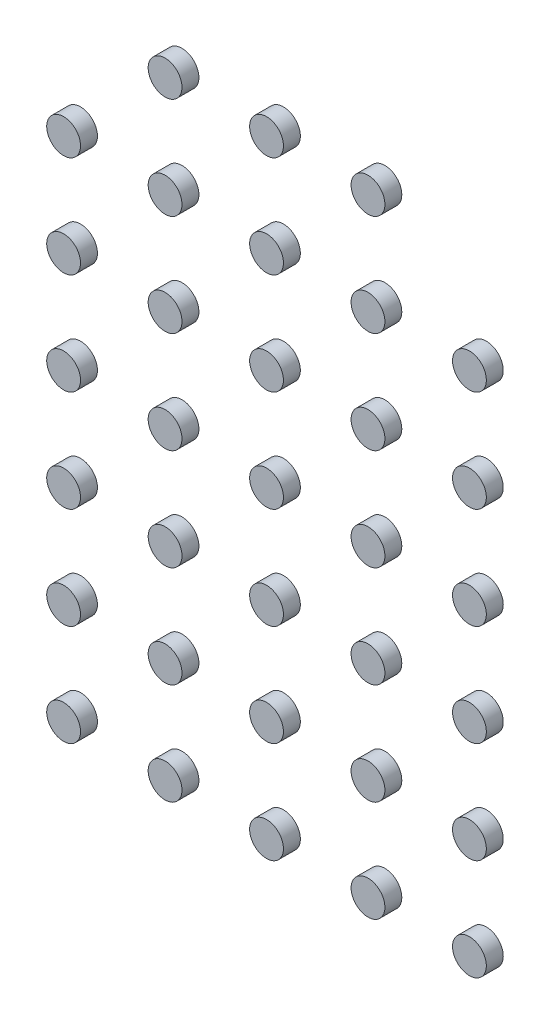
from build123d import *

# Parameters (mm, degrees)
SKETCH_4_R               = 0.5
EXTRUDE_2_DEPTH          = 0.5
PATTERN_LINEAR_1_COUNT   = 5
PATTERN_LINEAR_1_PITCH   = 3
PATTERN_LINEAR_1_2_COUNT = 6
PATTERN_LINEAR_1_2_PITCH = 3
PATTERN_LINEAR_2_COUNT   = 5
PATTERN_LINEAR_2_PITCH   = 3
PATTERN_LINEAR_2_2_COUNT = 2
PATTERN_LINEAR_2_2_PITCH = 3


with BuildPart() as part:
    # 草图4 → 凸台-拉伸2 (new body)
    with BuildSketch(Plane.XY):
        Circle(SKETCH_4_R)
    extrude(amount=EXTRUDE_2_DEPTH)


with BuildPart() as pattern_linear_1_1:
    # 阵列(线性)1: pattern copy
    add(part.part.moved(Location(Vector(1, 0, 0) * (1 * PATTERN_LINEAR_1_PITCH))))


with BuildPart() as pattern_linear_1_2:
    # 阵列(线性)1: pattern copy
    add(part.part.moved(Location(Vector(1, 0, 0) * (2 * PATTERN_LINEAR_1_PITCH))))


with BuildPart() as pattern_linear_1_3:
    # 阵列(线性)1: pattern copy
    add(part.part.moved(Location(Vector(1, 0, 0) * (3 * PATTERN_LINEAR_1_PITCH))))


with BuildPart() as pattern_linear_1_4:
    # 阵列(线性)1: pattern copy
    add(part.part.moved(Location(Vector(1, 0, 0) * (4 * PATTERN_LINEAR_1_PITCH))))


with BuildPart() as pattern_linear_1_2_1:
    # Pattern Linear 1 2: pattern copy
    add(part.part.moved(Location(Vector(0, 1, 0) * (1 * PATTERN_LINEAR_1_2_PITCH))))


with BuildPart() as pattern_linear_1_2_2:
    # Pattern Linear 1 2: pattern copy
    add(part.part.moved(Location(Vector(0, 1, 0) * (2 * PATTERN_LINEAR_1_2_PITCH))))


with BuildPart() as pattern_linear_1_2_3:
    # Pattern Linear 1 2: pattern copy
    add(part.part.moved(Location(Vector(0, 1, 0) * (3 * PATTERN_LINEAR_1_2_PITCH))))


with BuildPart() as pattern_linear_1_2_4:
    # Pattern Linear 1 2: pattern copy
    add(part.part.moved(Location(Vector(0, 1, 0) * (4 * PATTERN_LINEAR_1_2_PITCH))))


with BuildPart() as pattern_linear_1_2_5:
    # Pattern Linear 1 2: pattern copy
    add(part.part.moved(Location(Vector(0, 1, 0) * (5 * PATTERN_LINEAR_1_2_PITCH))))


with BuildPart() as pattern_linear_1_2_6:
    # Pattern Linear 1 2: pattern copy
    add(pattern_linear_1_1.part.moved(Location(Vector(0, 1, 0) * (1 * PATTERN_LINEAR_1_2_PITCH))))


with BuildPart() as pattern_linear_1_2_7:
    # Pattern Linear 1 2: pattern copy
    add(pattern_linear_1_1.part.moved(Location(Vector(0, 1, 0) * (2 * PATTERN_LINEAR_1_2_PITCH))))


with BuildPart() as pattern_linear_1_2_8:
    # Pattern Linear 1 2: pattern copy
    add(pattern_linear_1_1.part.moved(Location(Vector(0, 1, 0) * (3 * PATTERN_LINEAR_1_2_PITCH))))


with BuildPart() as pattern_linear_1_2_9:
    # Pattern Linear 1 2: pattern copy
    add(pattern_linear_1_1.part.moved(Location(Vector(0, 1, 0) * (4 * PATTERN_LINEAR_1_2_PITCH))))


with BuildPart() as pattern_linear_1_2_10:
    # Pattern Linear 1 2: pattern copy
    add(pattern_linear_1_1.part.moved(Location(Vector(0, 1, 0) * (5 * PATTERN_LINEAR_1_2_PITCH))))


with BuildPart() as pattern_linear_1_2_11:
    # Pattern Linear 1 2: pattern copy
    add(pattern_linear_1_2.part.moved(Location(Vector(0, 1, 0) * (1 * PATTERN_LINEAR_1_2_PITCH))))


with BuildPart() as pattern_linear_1_2_12:
    # Pattern Linear 1 2: pattern copy
    add(pattern_linear_1_2.part.moved(Location(Vector(0, 1, 0) * (2 * PATTERN_LINEAR_1_2_PITCH))))


with BuildPart() as pattern_linear_1_2_13:
    # Pattern Linear 1 2: pattern copy
    add(pattern_linear_1_2.part.moved(Location(Vector(0, 1, 0) * (3 * PATTERN_LINEAR_1_2_PITCH))))


with BuildPart() as pattern_linear_1_2_14:
    # Pattern Linear 1 2: pattern copy
    add(pattern_linear_1_2.part.moved(Location(Vector(0, 1, 0) * (4 * PATTERN_LINEAR_1_2_PITCH))))


with BuildPart() as pattern_linear_1_2_15:
    # Pattern Linear 1 2: pattern copy
    add(pattern_linear_1_2.part.moved(Location(Vector(0, 1, 0) * (5 * PATTERN_LINEAR_1_2_PITCH))))


with BuildPart() as pattern_linear_1_2_16:
    # Pattern Linear 1 2: pattern copy
    add(pattern_linear_1_3.part.moved(Location(Vector(0, 1, 0) * (1 * PATTERN_LINEAR_1_2_PITCH))))


with BuildPart() as pattern_linear_1_2_17:
    # Pattern Linear 1 2: pattern copy
    add(pattern_linear_1_3.part.moved(Location(Vector(0, 1, 0) * (2 * PATTERN_LINEAR_1_2_PITCH))))


with BuildPart() as pattern_linear_1_2_18:
    # Pattern Linear 1 2: pattern copy
    add(pattern_linear_1_3.part.moved(Location(Vector(0, 1, 0) * (3 * PATTERN_LINEAR_1_2_PITCH))))


with BuildPart() as pattern_linear_1_2_19:
    # Pattern Linear 1 2: pattern copy
    add(pattern_linear_1_3.part.moved(Location(Vector(0, 1, 0) * (4 * PATTERN_LINEAR_1_2_PITCH))))


with BuildPart() as pattern_linear_1_2_20:
    # Pattern Linear 1 2: pattern copy
    add(pattern_linear_1_3.part.moved(Location(Vector(0, 1, 0) * (5 * PATTERN_LINEAR_1_2_PITCH))))


with BuildPart() as pattern_linear_1_2_21:
    # Pattern Linear 1 2: pattern copy
    add(pattern_linear_1_4.part.moved(Location(Vector(0, 1, 0) * (1 * PATTERN_LINEAR_1_2_PITCH))))


with BuildPart() as pattern_linear_1_2_22:
    # Pattern Linear 1 2: pattern copy
    add(pattern_linear_1_4.part.moved(Location(Vector(0, 1, 0) * (2 * PATTERN_LINEAR_1_2_PITCH))))


with BuildPart() as pattern_linear_1_2_23:
    # Pattern Linear 1 2: pattern copy
    add(pattern_linear_1_4.part.moved(Location(Vector(0, 1, 0) * (3 * PATTERN_LINEAR_1_2_PITCH))))


with BuildPart() as pattern_linear_1_2_24:
    # Pattern Linear 1 2: pattern copy
    add(pattern_linear_1_4.part.moved(Location(Vector(0, 1, 0) * (4 * PATTERN_LINEAR_1_2_PITCH))))


with BuildPart() as pattern_linear_1_2_25:
    # Pattern Linear 1 2: pattern copy
    add(pattern_linear_1_4.part.moved(Location(Vector(0, 1, 0) * (5 * PATTERN_LINEAR_1_2_PITCH))))


with BuildPart() as pattern_linear_2_1:
    # 阵列(线性)2: pattern copy
    add(part.part.moved(Location(Vector(1, 0, 0) * (1 * PATTERN_LINEAR_2_PITCH))))


with BuildPart() as pattern_linear_2_2:
    # 阵列(线性)2: pattern copy
    add(part.part.moved(Location(Vector(1, 0, 0) * (2 * PATTERN_LINEAR_2_PITCH))))


with BuildPart() as pattern_linear_2_3:
    # 阵列(线性)2: pattern copy
    add(part.part.moved(Location(Vector(1, 0, 0) * (3 * PATTERN_LINEAR_2_PITCH))))


with BuildPart() as pattern_linear_2_4:
    # 阵列(线性)2: pattern copy
    add(part.part.moved(Location(Vector(1, 0, 0) * (4 * PATTERN_LINEAR_2_PITCH))))


with BuildPart() as pattern_linear_2_2_1:
    # Pattern Linear 2 2: pattern copy
    add(part.part.moved(Location(Vector(0, -1, 0) * (1 * PATTERN_LINEAR_2_2_PITCH))))


with BuildPart() as pattern_linear_2_2_2:
    # Pattern Linear 2 2: pattern copy
    add(pattern_linear_2_1.part.moved(Location(Vector(0, -1, 0) * (1 * PATTERN_LINEAR_2_2_PITCH))))


with BuildPart() as pattern_linear_2_2_3:
    # Pattern Linear 2 2: pattern copy
    add(pattern_linear_2_2.part.moved(Location(Vector(0, -1, 0) * (1 * PATTERN_LINEAR_2_2_PITCH))))


with BuildPart() as pattern_linear_2_2_4:
    # Pattern Linear 2 2: pattern copy
    add(pattern_linear_2_3.part.moved(Location(Vector(0, -1, 0) * (1 * PATTERN_LINEAR_2_2_PITCH))))


with BuildPart() as pattern_linear_2_2_5:
    # Pattern Linear 2 2: pattern copy
    add(pattern_linear_2_4.part.moved(Location(Vector(0, -1, 0) * (1 * PATTERN_LINEAR_2_2_PITCH))))


solid = Compound([part.part, pattern_linear_1_1.part, pattern_linear_1_2.part, pattern_linear_1_3.part, pattern_linear_1_4.part, pattern_linear_1_2_1.part, pattern_linear_1_2_2.part, pattern_linear_1_2_3.part, pattern_linear_1_2_4.part, pattern_linear_1_2_6.part, pattern_linear_1_2_7.part, pattern_linear_1_2_8.part, pattern_linear_1_2_9.part, pattern_linear_1_2_10.part, pattern_linear_1_2_11.part, pattern_linear_1_2_12.part, pattern_linear_1_2_13.part, pattern_linear_1_2_14.part, pattern_linear_1_2_15.part, pattern_linear_1_2_16.part, pattern_linear_1_2_17.part, pattern_linear_1_2_18.part, pattern_linear_1_2_19.part, pattern_linear_1_2_20.part, pattern_linear_1_2_21.part, pattern_linear_1_2_22.part, pattern_linear_1_2_23.part, pattern_linear_1_2_24.part, pattern_linear_2_1.part, pattern_linear_2_2.part, pattern_linear_2_3.part, pattern_linear_2_4.part, pattern_linear_2_2_1.part, pattern_linear_2_2_2.part, pattern_linear_2_2_3.part, pattern_linear_2_2_4.part, pattern_linear_2_2_5.part])
